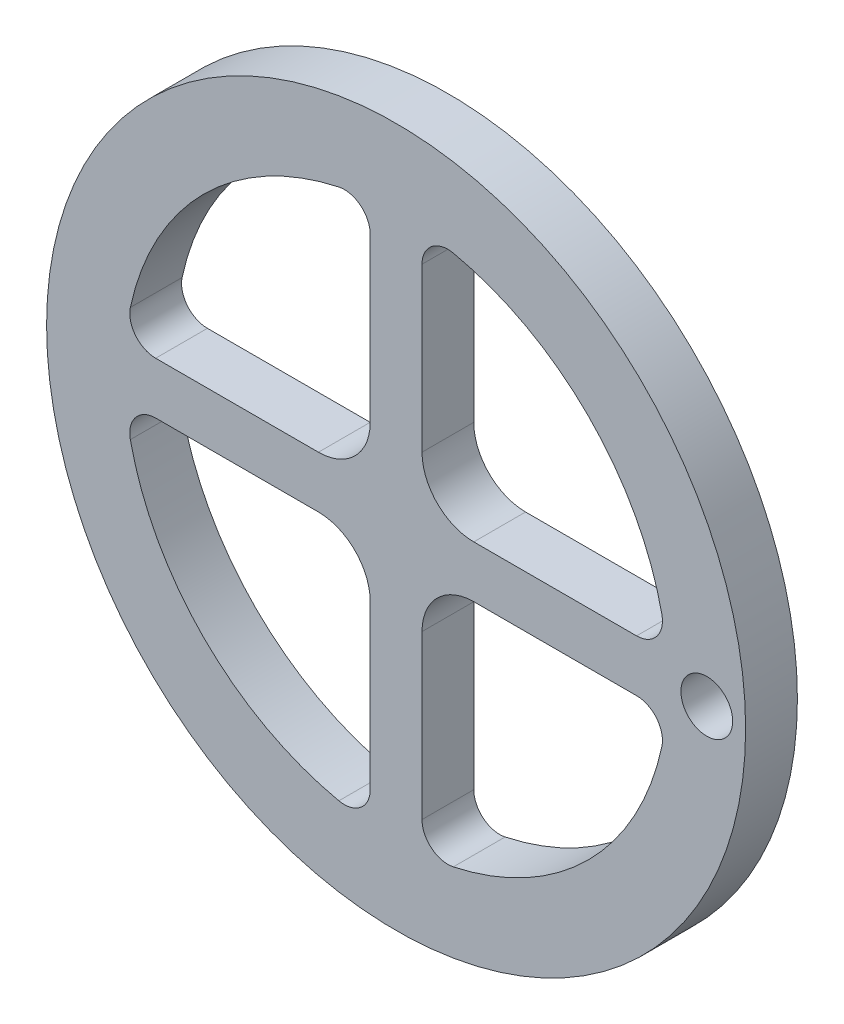
from build123d import *

# Parameters (mm, degrees)
SKETCH2_R           = 27
SKETCH2_R_2         = 2
BOSS_EXTRUDE1_DEPTH = 4


with BuildPart() as part:
    # Sketch2 → Boss-Extrude1 (new body)
    with BuildSketch(Plane.XY):
        Circle(SKETCH2_R)
        with Locations((24, 0)):
            Circle(SKETCH2_R_2, mode=Mode.SUBTRACT)
        with BuildLine():
            Line((-2, 18.574175621), (-2, 6))
            ThreePointArc((-2, 6), (-3.171572875, 3.171572875), (-6, 2))
            Line((-6, 2), (-18.574175621, 2))
            ThreePointArc((-18.574175621, 2), (-20.130148831, 2.743438275), (-20.529352002, 4.421052632))
            ThreePointArc((-20.529352002, 4.421052632), (-14.849242405, 14.849242405), (-4.421052632, 20.529352002))
            ThreePointArc((-4.421052632, 20.529352002), (-2.743438275, 20.130148831), (-2, 18.574175621))
        make_face(mode=Mode.SUBTRACT)
        with BuildLine():
            Line((18.574175621, 2), (6, 2))
            ThreePointArc((6, 2), (3.171572875, 3.171572875), (2, 6))
            Line((2, 6), (2, 18.574175621))
            ThreePointArc((2, 18.574175621), (2.743438275, 20.130148831), (4.421052632, 20.529352002))
            ThreePointArc((4.421052632, 20.529352002), (14.849242405, 14.849242405), (20.529352002, 4.421052632))
            ThreePointArc((20.529352002, 4.421052632), (20.130148831, 2.743438275), (18.574175621, 2))
        make_face(mode=Mode.SUBTRACT)
        with BuildLine():
            Line((18.574175621, -2), (6, -2))
            ThreePointArc((6, -2), (3.171572875, -3.171572875), (2, -6))
            Line((2, -6), (2, -18.574175621))
            ThreePointArc((2, -18.574175621), (2.743438275, -20.130148831), (4.421052632, -20.529352002))
            ThreePointArc((4.421052632, -20.529352002), (14.849242405, -14.849242405), (20.529352002, -4.421052632))
            ThreePointArc((20.529352002, -4.421052632), (20.130148831, -2.743438275), (18.574175621, -2))
        make_face(mode=Mode.SUBTRACT)
        with BuildLine():
            Line((-6, -2), (-18.574175621, -2))
            ThreePointArc((-18.574175621, -2), (-20.130148831, -2.743438275), (-20.529352002, -4.421052632))
            ThreePointArc((-20.529352002, -4.421052632), (-14.849242405, -14.849242405), (-4.421052632, -20.529352002))
            ThreePointArc((-4.421052632, -20.529352002), (-2.743438275, -20.130148831), (-2, -18.574175621))
            Line((-2, -18.574175621), (-2, -6))
            ThreePointArc((-2, -6), (-3.171572875, -3.171572875), (-6, -2))
        make_face(mode=Mode.SUBTRACT)
    extrude(amount=BOSS_EXTRUDE1_DEPTH)


solid = part.part
